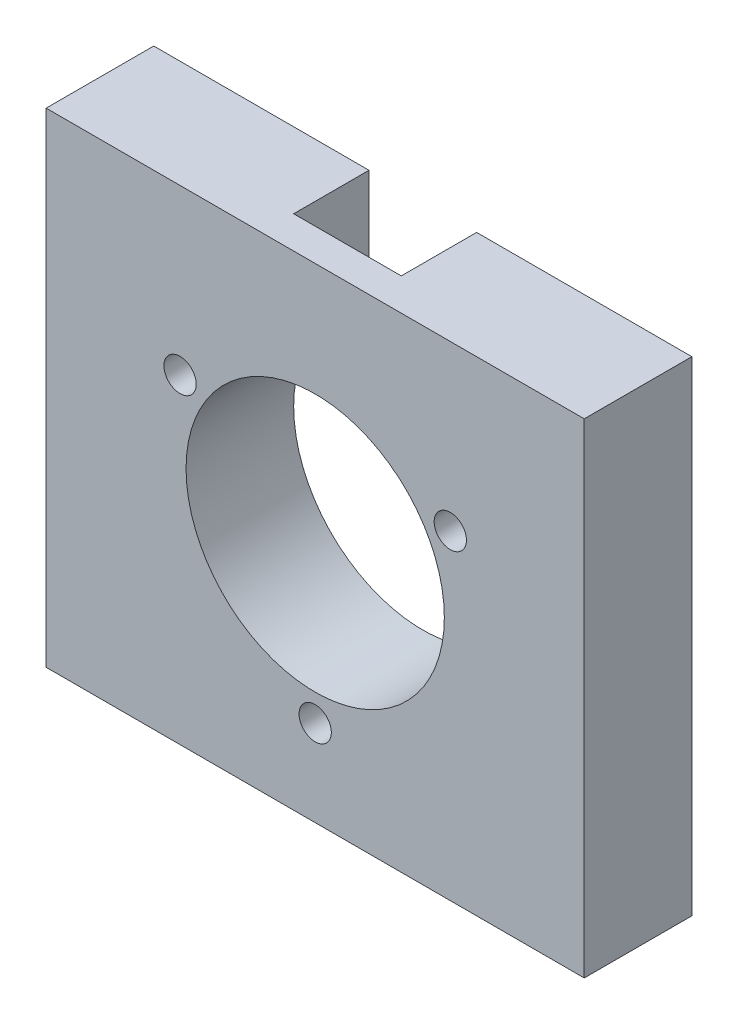
from build123d import *

# Parameters (mm, degrees)
ESQUISSE1_W      = 50
ESQUISSE1_H      = 10
EXTRUSION1_DEPTH = 45
ESQUISSE2_R      = 12
ESQUISSE2_R_2    = 1.5
EXTRUSION2_DEPTH = 45
EXTRUSION5_DEPTH = 7


with BuildPart() as part:
    # Esquisse1 → Extrusion1 (new body)
    with BuildSketch(Plane(origin=(0, 0, 0), x_dir=(1, 0, 0), z_dir=(0, 1, 0))):
        with Locations((25, -5)):
            Rectangle(ESQUISSE1_W, ESQUISSE1_H)
    extrude(amount=EXTRUSION1_DEPTH)

    # Esquisse2 → Extrusion2 (cut)
    with BuildSketch(Plane.XY.offset(10)):
        with Locations((25, 22.5)):
            Circle(ESQUISSE2_R)
        with Locations((12.445, 29.74863263)):
            Circle(ESQUISSE2_R_2)
        with Locations((37.555, 29.74863263)):
            Circle(ESQUISSE2_R_2)
        with Locations((25, 8.002734741)):
            Circle(ESQUISSE2_R_2)
    extrude(amount=-EXTRUSION2_DEPTH, mode=Mode.SUBTRACT)

    # Esquisse3 → Extrusion5 (cut)
    with BuildSketch(Plane.XY):
        with BuildLine():
            Line((30, 33.408712115), (30, 45))
            Line((30, 45), (20, 45))
            Line((20, 45), (20, 33.408712115))
            ThreePointArc((20, 33.408712115), (25, 34.5), (30, 33.408712115))
        make_face()
    extrude(amount=EXTRUSION5_DEPTH, mode=Mode.SUBTRACT)


solid = part.part
